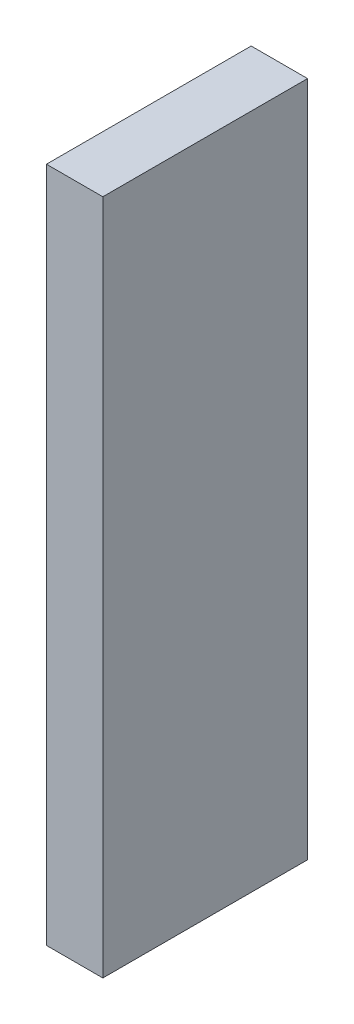
from build123d import *

# Parameters (mm, degrees)
SKETCH1_W           = 5.446085142
SKETCH1_H           = 17.99830505
BOSS_EXTRUDE1_DEPTH = 1.5


with BuildPart() as part:
    # Sketch1 → Boss-Extrude1 (new body)
    with BuildSketch(Plane(origin=(675, 0, 0), x_dir=(0, 0, -1), z_dir=(1, 0, 0))):
        with Locations((-4.532913038, 914.216540649)):
            Rectangle(SKETCH1_W, SKETCH1_H)
    extrude(amount=-BOSS_EXTRUDE1_DEPTH)


solid = part.part
